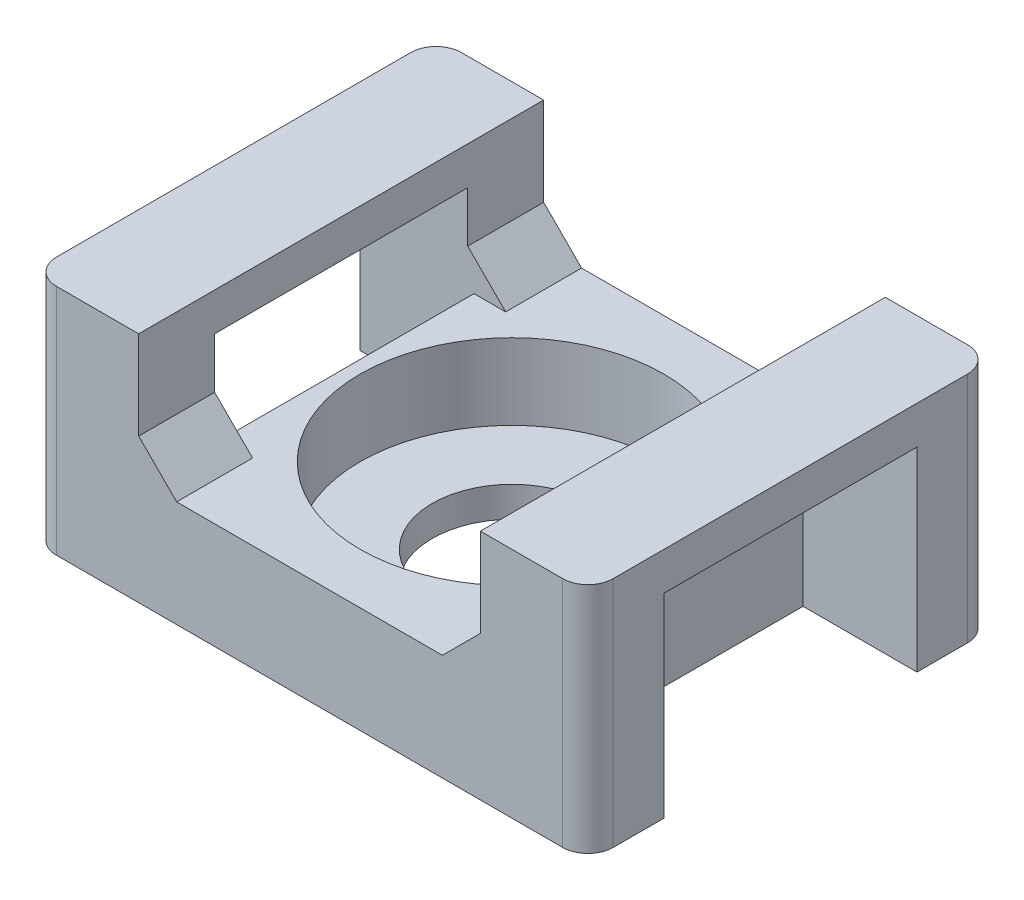
from build123d import *

# Parameters (mm, degrees)
EXTRUDE_1_DEPTH             = 8
CUT_EXTRUDE_1_DEPTH         = 5
HOLE_WIZARD_M61_D           = 6.3
HOLE_WIZARD_M61_DEPTH       = 4.2
HOLE_WIZARD_M61_CBORE_D     = 12
HOLE_WIZARD_M61_CBORE_DEPTH = 3
FILLET_1_R                  = 1


with BuildPart() as part:
    # Эскиз1 → Бобышка-Вытянуть1 (new body, symmetric)
    with BuildSketch(Plane.XY):
        Polygon((11, 0), (-11, 0), (-11, 9.2), (-6.75, 9.2), (-6.75, 5.7), (-5.25, 4.2), (5.25, 4.2), (6.75, 5.7), (6.75, 9.2), (11, 9.2), align=None)
    extrude(amount=EXTRUDE_1_DEPTH, both=True)

    # Эскиз2 → Вырез-Вытянуть1 (cut, symmetric)
    with BuildSketch(Plane.XY):
        Polygon((-11, 7.7), (-6.75, 7.7), (-6.75, 5.7), (-5.25, 4.2), (-6.5, 4.2), (-6.5, 0), (-11, 0), align=None)
    cut_extrude_1 = extrude(amount=CUT_EXTRUDE_1_DEPTH, both=True, mode=Mode.SUBTRACT)

    # Зеркальное отражение1: Вырез-Вытянуть1 across plane
    add(cut_extrude_1.mirror(Plane(origin=(0, 0, 0), x_dir=(0, 0, 1), z_dir=(1, 0, 0))), mode=Mode.SUBTRACT)

    # Цековка для  болта с шестигранной головкой M61
    with Locations(Plane(origin=(0, 4.2, 0), x_dir=(1, 0, 0), z_dir=(0, 1, 0))):
        with Locations((0, 0)):
            CounterBoreHole(HOLE_WIZARD_M61_D / 2, HOLE_WIZARD_M61_CBORE_D / 2, HOLE_WIZARD_M61_CBORE_DEPTH, depth=HOLE_WIZARD_M61_DEPTH)

    # Скругление1
    fillet_1_edges = [part.edges().sort_by_distance(p)[0] for p in [
        (11, 4.6, 8),
        (11, 4.6, -8),
        (-11, 4.6, -8),
        (-11, 4.6, 8),
    ]]
    fillet(fillet_1_edges, radius=FILLET_1_R)


solid = part.part
